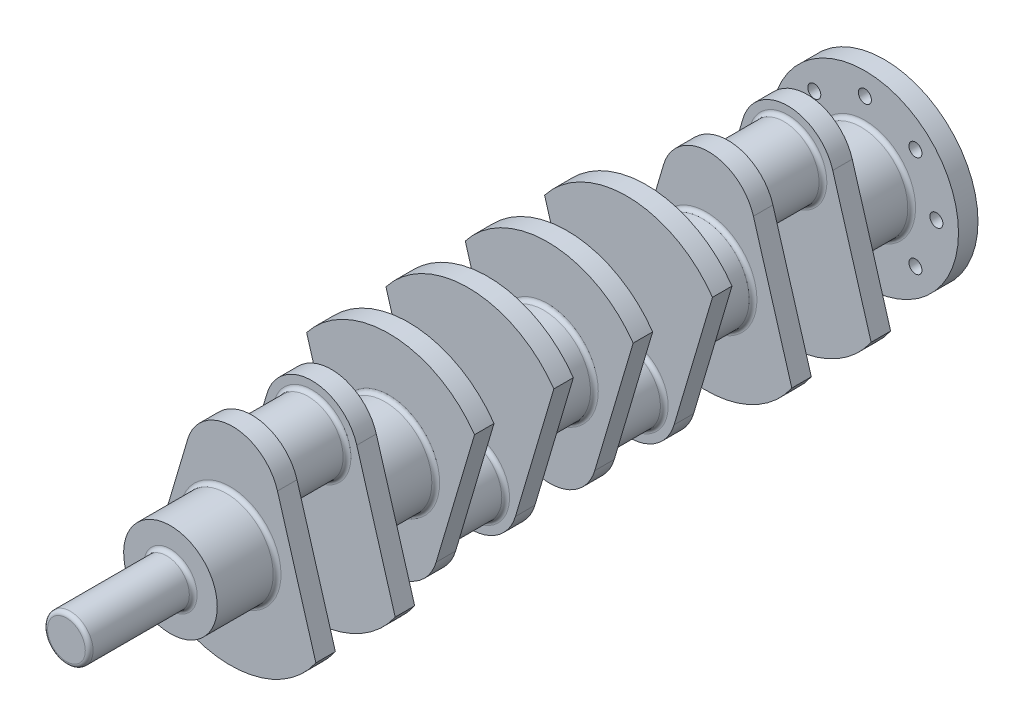
from build123d import *

# Parameters (mm, degrees)
BOSS_EXTRUDE1_DEPTH   = 15
SKETCH3_R             = 27
BOSS_EXTRUDE2_DEPTH   = 46
SKETCH5_R             = 36
BOSS_EXTRUDE3_DEPTH   = 46
BODY_MOVE_COPY1_ANGLE = 180
SKETCH7_R             = 17.5
BOSS_EXTRUDE4_DEPTH   = 80
SKETCH8_R             = 72
SKETCH8_R_2           = 5
BOSS_EXTRUDE6_DEPTH   = 15
FILLET1_R             = 3


with BuildPart() as part:
    # Sketch1 → Boss-Extrude1 (new body)
    with BuildSketch(Plane.XY):
        with BuildLine():
            Line((-63.297975399, 48.922043195), (-32.744561821, -54.224552409))
            ThreePointArc((-32.744561821, -54.224552409), (1.772948634, -80), (36.290459089, -54.224552409))
            Line((36.290459089, -54.224552409), (65.821402699, 45.470242432))
            ThreePointArc((65.821402699, 45.470242432), (2.137908666, 79.971428314), (-63.297975399, 48.922043195))
        make_face()
    extrude(amount=BOSS_EXTRUDE1_DEPTH)

    # Sketch3 → Boss-Extrude2 (add)
    with BuildSketch(Plane(origin=(0, 0, 0), x_dir=(-1, 0, 0), z_dir=(0, 0, -1))):
        with Locations((-1.772948634, -44)):
            Circle(SKETCH3_R)
    extrude(amount=BOSS_EXTRUDE2_DEPTH)

    # Sketch5 → Boss-Extrude3 (add)
    with BuildSketch(Plane.XY.offset(15)):
        Circle(SKETCH5_R)
    extrude(amount=BOSS_EXTRUDE3_DEPTH)

    # Mirror1: part across plane


with BuildPart() as part_1:
    add(part.part)
    add(part.part.mirror(Plane(origin=(0, 0, -23), x_dir=(1, 0, 0), z_dir=(0, 0, -1))))


with BuildPart() as body_2:
    # Mirror2: mirrored copy
    add(part_1.part.mirror(Plane(origin=(0, 0, -84), x_dir=(1, 0, 0), z_dir=(0, 0, -1))))


with BuildPart() as body_2_1:
    # Body-Move/Copy1: moved
    add(body_2.part.rotate(Axis((0, 0, -145), (1, 0, 0)), BODY_MOVE_COPY1_ANGLE))


with BuildPart() as body_3:
    # Mirror3: mirrored copy
    add(body_2_1.part.mirror(Plane.XY.offset(38)))

    # Sketch7 → Boss-Extrude4 (add)
    with BuildSketch(Plane.XY.offset(305)):
        Circle(SKETCH7_R)
    extrude(amount=BOSS_EXTRUDE4_DEPTH)


with BuildPart() as body_4:
    # Mirror3 2: mirrored copy
    add(part_1.part.mirror(Plane.XY.offset(38)))


with BuildPart() as body_2_2:
    add(body_2_1.part)

    # Sketch8 → Boss-Extrude6 (add)
    with BuildSketch(Plane(origin=(0, 0, -229), x_dir=(-1, 0, 0), z_dir=(0, 0, -1))):
        Circle(SKETCH8_R)
        with Locations((0, 55)):
            Circle(SKETCH8_R_2, mode=Mode.SUBTRACT)
        with Locations((38.890872965, 38.890872965)):
            Circle(SKETCH8_R_2, mode=Mode.SUBTRACT)
        with Locations((55, 0)):
            Circle(SKETCH8_R_2, mode=Mode.SUBTRACT)
        with Locations((38.890872965, -38.890872965)):
            Circle(SKETCH8_R_2, mode=Mode.SUBTRACT)
        with Locations((0, -55)):
            Circle(SKETCH8_R_2, mode=Mode.SUBTRACT)
        with Locations((-38.890872965, -38.890872965)):
            Circle(SKETCH8_R_2, mode=Mode.SUBTRACT)
        with Locations((-55, 0)):
            Circle(SKETCH8_R_2, mode=Mode.SUBTRACT)
        with Locations((-38.890872965, 38.890872965)):
            Circle(SKETCH8_R_2, mode=Mode.SUBTRACT)
    extrude(amount=BOSS_EXTRUDE6_DEPTH)

    # Combine1: union part, body 4, body 3
    add(part_1.part)
    add(body_4.part)
    add(body_3.part)

    # Fillet1
    fillet1_edges = [body_2_2.edges().sort_by_distance(p)[0] for p in [
        (28.772948634, 44, -122),
        (28.772948634, 44, -168),
        (-36, 0, -107),
        (-36, 0, -183),
        (-36, 0, -229),
        (28.772948634, -44, 0),
        (-36, 0, 15),
        (-36, 0, -61),
        (28.772948634, -44, -46),
        (-36, 0, 61),
        (28.772948634, -44, 76),
        (28.772948634, -44, 122),
        (-36, 0, 137),
        (-36, 0, 183),
        (28.772948634, 44, 198),
        (-36, 0, 259),
        (28.772948634, 44, 244),
        (-17.5, 0, 305),
        (-17.5, 0, 385),
    ]]
    fillet(fillet1_edges, radius=FILLET1_R)


solid = body_2_2.part
